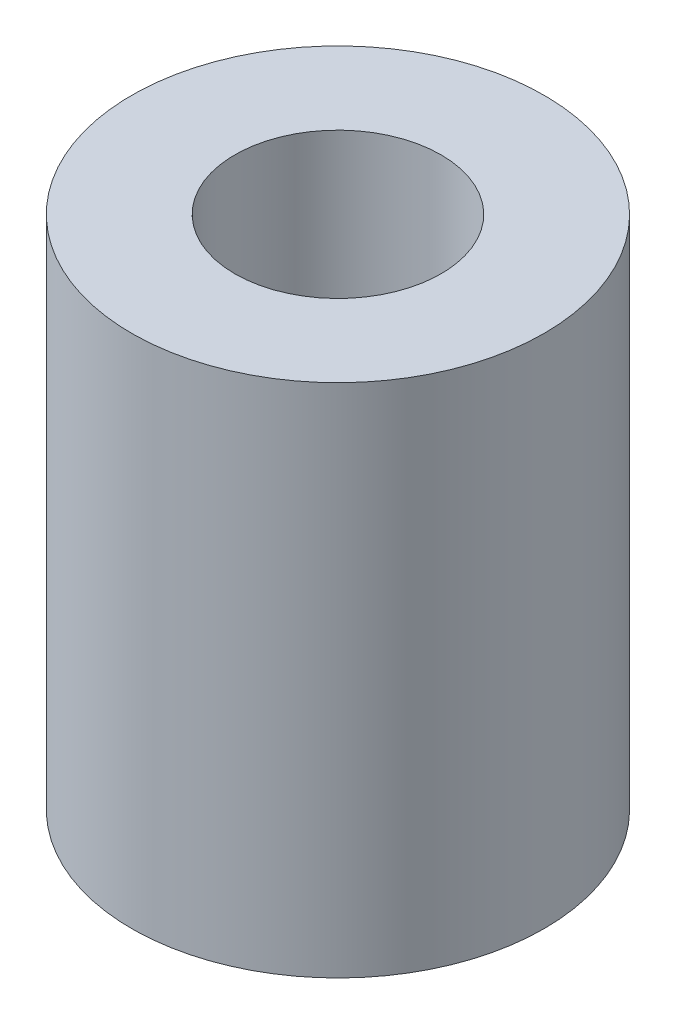
from build123d import *

# Parameters (mm, degrees)
SKETCH1_R           = 4
SKETCH1_R_2         = 2
EXTRUDE_THIN1_DEPTH = 10


with BuildPart() as part:
    # Sketch1 → Extrude-Thin1 (new body)
    with BuildSketch(Plane(origin=(0, 0, 0), x_dir=(1, 0, 0), z_dir=(0, 1, 0))):
        Circle(SKETCH1_R)
        Circle(SKETCH1_R_2, mode=Mode.SUBTRACT)
    extrude(amount=EXTRUDE_THIN1_DEPTH)


solid = part.part
